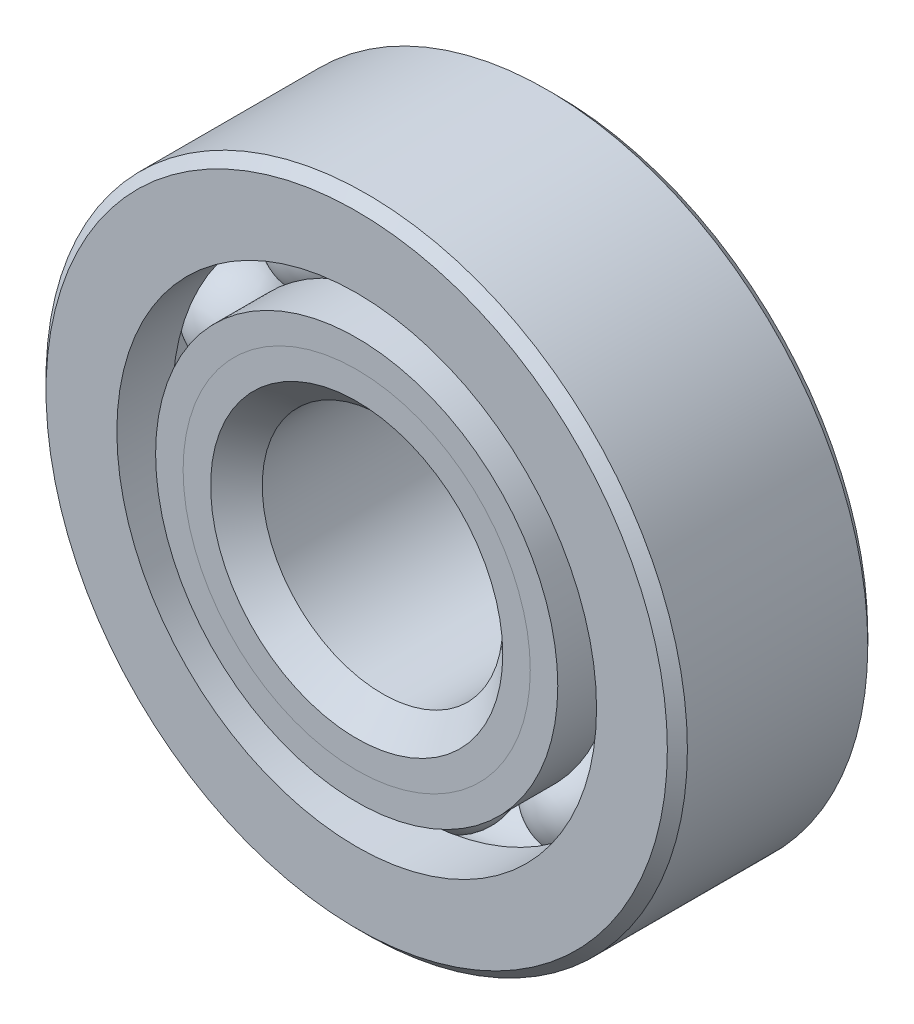
from build123d import *

# Parameters (mm, degrees)
CIRPATTERN1_COUNT = 10


with BuildPart() as part:
    # Sketch1 → Revolve1 (revolve)
    with BuildSketch(Plane(origin=(0, 0, 0), x_dir=(0, 0, -1), z_dir=(1, 0, 0))):
        with BuildLine():
            Line((1.7859375, 6.35), (-1.7859375, 6.35))
            Line((-1.7859375, 6.35), (-1.984375, 6.1515625))
            Line((-1.984375, 6.1515625), (-1.984375, 4.749416209))
            Line((-1.984375, 4.749416209), (-0.881944444, 4.749416209))
            ThreePointArc((-0.881944444, 4.749416209), (0, 5.327457467), (0.881944444, 4.749416209))
            Line((0.881944444, 4.749416209), (1.984375, 4.749416209))
            Line((1.984375, 4.749416209), (1.984375, 6.1515625))
            Line((1.984375, 6.1515625), (1.7859375, 6.35))
        make_face()
    revolve(axis=Axis((0, 0, 1.984375), (0, 0, -1)))


with BuildPart() as body_2:
    # Sketch2 → Revolve2 (revolve)
    with BuildSketch(Plane(origin=(0, 0, 0), x_dir=(0, 0, -1), z_dir=(1, 0, 0))):
        with BuildLine():
            Line((-1.984375, 3.981833791), (-0.881944444, 3.981833791))
            ThreePointArc((-0.881944444, 3.981833791), (-0.527247025, 3.561179682), (0, 3.403792533))
            Line((0, 3.403792533), (0, 2.892521266))
            Line((0, 2.892521266), (-1.439718738, 2.892521266))
            Line((-1.439718738, 2.892521266), (-1.984375, 3.437177529))
            Line((-1.984375, 3.437177529), (-1.984375, 3.981833791))
        make_face()
    revolve(axis=Axis((0, 0, 1.984375), (0, 0, -1)))


with BuildPart() as body_3:
    # Sketch3 → Revolve3 (revolve)
    with BuildSketch(Plane(origin=(0, 0, 0), x_dir=(0, 0, -1), z_dir=(1, 0, 0))):
        with BuildLine():
            Line((-1.984375, 3.437177529), (-1.439718738, 2.892521266))
            Line((-1.439718738, 2.892521266), (0, 2.892521266))
            Line((0, 2.892521266), (0, 3.403792533))
            ThreePointArc((0, 3.403792533), (0.527247025, 3.561179682), (0.881944444, 3.981833791))
            Line((0.881944444, 3.981833791), (1.984375, 3.981833791))
            Line((1.984375, 3.981833791), (1.984375, 2.5796875))
            Line((1.984375, 2.5796875), (1.7859375, 2.38125))
            Line((1.7859375, 2.38125), (-1.473103734, 2.38125))
            Line((-1.473103734, 2.38125), (-1.984375, 2.892521266))
            Line((-1.984375, 2.892521266), (-1.984375, 3.437177529))
        make_face()
    revolve(axis=Axis((0, 0, 1.984375), (0, 0, -1)))


with BuildPart() as body_4:
    # Sketch4 → Revolve4 (revolve)
    with BuildSketch(Plane(origin=(0, 0, 0), x_dir=(0, 0, -1), z_dir=(1, 0, 0))):
        with BuildLine():
            Line((-0.961832467, 4.365625), (0.961832467, 4.365625))
            ThreePointArc((0.961832467, 4.365625), (0, 5.327457467), (-0.961832467, 4.365625))
        make_face()
    revolve(axis=Axis((0, 4.365625, 0.961832467), (0, 0, -1)))


with BuildPart() as cirpattern1_1:
    # CirPattern1: pattern copy
    add(body_4.part.rotate(Axis((0, 0, 0), (0, 0, 1)), 1 * 360 / CIRPATTERN1_COUNT))


with BuildPart() as cirpattern1_2:
    # CirPattern1: pattern copy
    add(body_4.part.rotate(Axis((0, 0, 0), (0, 0, 1)), 2 * 360 / CIRPATTERN1_COUNT))


with BuildPart() as cirpattern1_3:
    # CirPattern1: pattern copy
    add(body_4.part.rotate(Axis((0, 0, 0), (0, 0, 1)), 3 * 360 / CIRPATTERN1_COUNT))


with BuildPart() as cirpattern1_4:
    # CirPattern1: pattern copy
    add(body_4.part.rotate(Axis((0, 0, 0), (0, 0, 1)), 4 * 360 / CIRPATTERN1_COUNT))


with BuildPart() as cirpattern1_5:
    # CirPattern1: pattern copy
    add(body_4.part.rotate(Axis((0, 0, 0), (0, 0, 1)), 5 * 360 / CIRPATTERN1_COUNT))


with BuildPart() as cirpattern1_6:
    # CirPattern1: pattern copy
    add(body_4.part.rotate(Axis((0, 0, 0), (0, 0, 1)), 6 * 360 / CIRPATTERN1_COUNT))


with BuildPart() as cirpattern1_7:
    # CirPattern1: pattern copy
    add(body_4.part.rotate(Axis((0, 0, 0), (0, 0, 1)), 7 * 360 / CIRPATTERN1_COUNT))


with BuildPart() as cirpattern1_8:
    # CirPattern1: pattern copy
    add(body_4.part.rotate(Axis((0, 0, 0), (0, 0, 1)), 8 * 360 / CIRPATTERN1_COUNT))


with BuildPart() as cirpattern1_9:
    # CirPattern1: pattern copy
    add(body_4.part.rotate(Axis((0, 0, 0), (0, 0, 1)), 9 * 360 / CIRPATTERN1_COUNT))


solid = Compound([part.part, body_2.part, body_3.part, body_4.part, cirpattern1_1.part, cirpattern1_2.part, cirpattern1_3.part, cirpattern1_4.part, cirpattern1_5.part, cirpattern1_6.part, cirpattern1_7.part, cirpattern1_8.part, cirpattern1_9.part])
